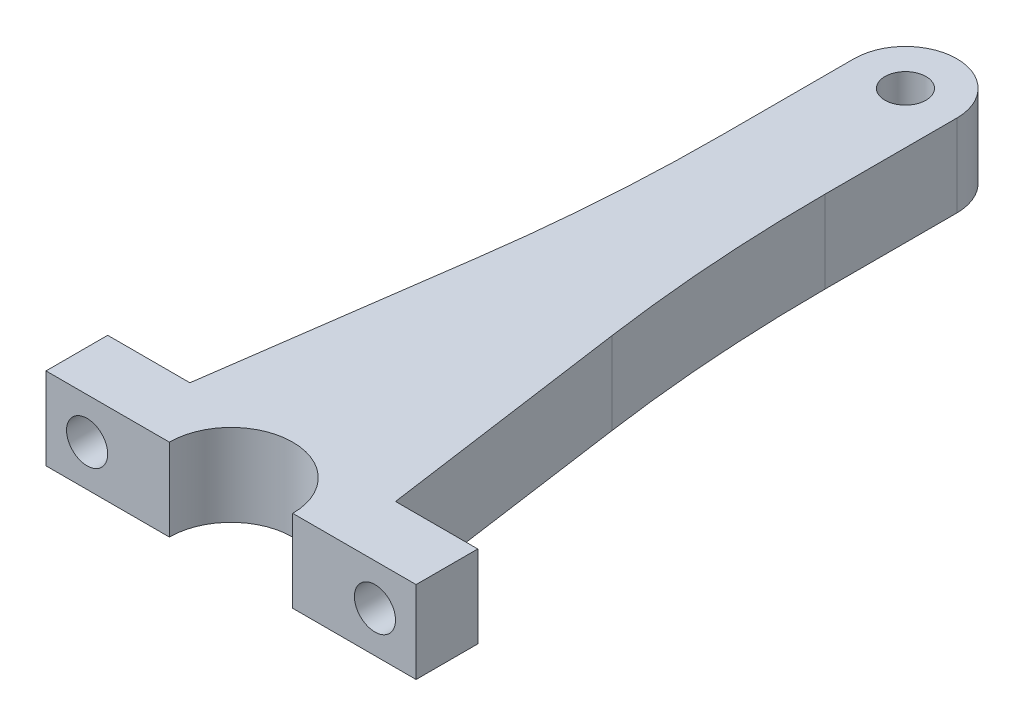
from build123d import *

# Parameters (mm, degrees)
BOSS_EXTRUDE1_DEPTH = 20
SKETCH2_R           = 5
CUT_EXTRUDE1_DEPTH  = 16
FILLET1_R           = 400


with BuildPart() as part:
    # Sketch1 → Boss-Extrude1 (new body)
    with BuildSketch(Plane(origin=(0, 0, 0), x_dir=(1, 0, 0), z_dir=(0, 1, 0))):
        with BuildLine():
            ThreePointArc((12.5, 156.5), (0, 169), (-12.5, 156.5))
            Line((-12.5, 156.5), (-5, 156.5))
            ThreePointArc((-5, 156.5), (0, 161.5), (5, 156.5))
            Line((5, 156.5), (12.5, 156.5))
        make_face()
        with BuildLine():
            Line((-5, 156.5), (-12.5, 156.5))
            ThreePointArc((-12.5, 156.5), (0, 144), (12.5, 156.5))
            Line((12.5, 156.5), (5, 156.5))
            ThreePointArc((5, 156.5), (0, 151.5), (-5, 156.5))
        make_face()
        with BuildLine():
            Line((-12.5, 156.5), (-12.5, 96.44212153))
            Line((-12.5, 96.44212153), (12.5, 96.44212153))
            Line((12.5, 96.44212153), (12.5, 156.5))
            ThreePointArc((12.5, 156.5), (0, 144), (-12.5, 156.5))
        make_face()
        Polygon((-12.5, 96.44212153), (-25, 7.5), (-2.3e-08, 7.5), (25, 7.5), (12.5, 96.44212153), align=None)
        with BuildLine():
            Line((-2.3e-08, 7.5), (-25, 7.5))
            Line((-25, 7.5), (-45, 7.5))
            Line((-45, 7.5), (-45, -7.5))
            Line((-45, -7.5), (-15, -7.5))
            ThreePointArc((-15, -7.5), (-10.606601726, 3.10660171), (-2.3e-08, 7.5))
        make_face()
        with BuildLine():
            Line((25, 7.5), (-2.3e-08, 7.5))
            ThreePointArc((-2.3e-08, 7.5), (10.60660171, 3.106601726), (15, -7.5))
            Line((15, -7.5), (45, -7.5))
            Line((45, -7.5), (45, 7.5))
            Line((45, 7.5), (25, 7.5))
        make_face()
    extrude(amount=BOSS_EXTRUDE1_DEPTH)

    # Sketch2 → Cut-Extrude1 (cut, through all)
    with BuildSketch(Plane(origin=(0, 0, -7.5), x_dir=(-1, 0, 0), z_dir=(0, 0, -1))):
        with Locations((35, 10)):
            Circle(SKETCH2_R)
        with Locations((-35, 10)):
            Circle(SKETCH2_R)
    extrude(amount=-CUT_EXTRUDE1_DEPTH, mode=Mode.SUBTRACT)

    # Fillet1
    fillet1_edges = [part.edges().sort_by_distance(p)[0] for p in [
        (12.5, 10, -96.44212153),
        (-12.5, 10, -96.44212153),
    ]]
    fillet(fillet1_edges, radius=FILLET1_R)


solid = part.part
